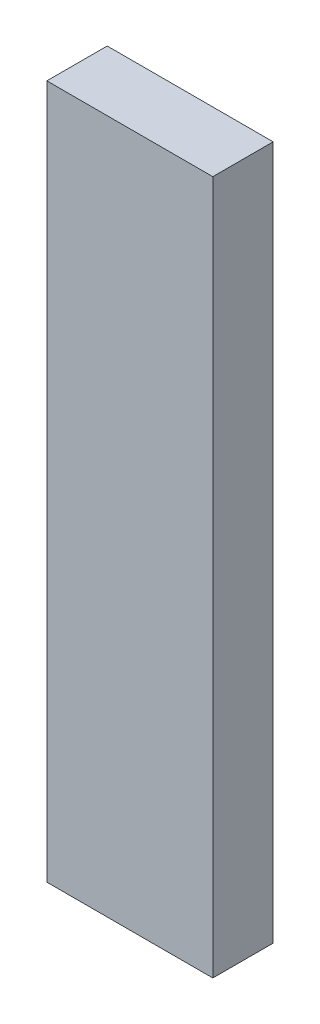
from build123d import *

# Parameters (mm, degrees)
SKETCH_1_W      = 55
SKETCH_1_H      = 20
EXTRUDE_1_DEPTH = 230


with BuildPart() as part:
    # Эскиз1 → Бобышка-Вытянуть1 (new body)
    with BuildSketch(Plane(origin=(0, 0, 0), x_dir=(1, 0, 0), z_dir=(0, 1, 0))):
        Rectangle(SKETCH_1_W, SKETCH_1_H)
    extrude(amount=EXTRUDE_1_DEPTH)


solid = part.part
